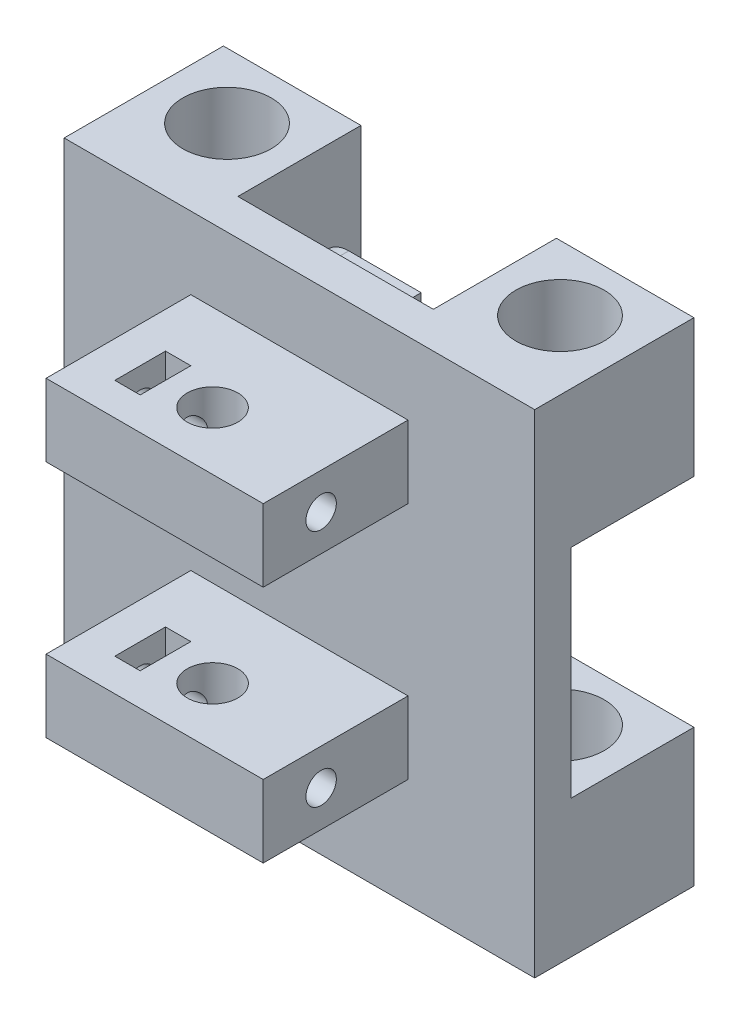
from build123d import *

# Parameters (mm, degrees)
SKETCH1_W           = 19
SKETCH1_H           = 17
SKETCH1_R           = 6.1
BOSS_EXTRUDE1_DEPTH = 68
SKETCH3_W           = 65
SKETCH3_H           = 30
CUT_EXTRUDE1_DEPTH  = 17
SKETCH4_W           = 5
SKETCH4_H           = 4
BOSS_EXTRUDE2_DEPTH = 3
SKETCH5_W           = 30
SKETCH5_H           = 10
BOSS_EXTRUDE3_DEPTH = 20
SKETCH6_R           = 3.5
CUT_EXTRUDE2_DEPTH  = 59
SKETCH8_R           = 2.1
CUT_EXTRUDE3_DEPTH  = 48.5
SKETCH9_W           = 3.5
SKETCH9_H           = 7
CUT_EXTRUDE4_DEPTH  = 43


with BuildPart() as part:
    # Sketch1 → Boss-Extrude1 (new body)
    with BuildSketch(Plane(origin=(0, 0, 0), x_dir=(1, 0, 0), z_dir=(0, 1, 0))):
        with Locations((-23, 0.5)):
            Rectangle(SKETCH1_W, SKETCH1_H)
        with Locations((-23, 0)):
            Circle(SKETCH1_R, mode=Mode.SUBTRACT)
        with Locations((23, 0.5)):
            Rectangle(SKETCH1_W, SKETCH1_H)
        with Locations((23, 0)):
            Circle(SKETCH1_R, mode=Mode.SUBTRACT)
        Polygon((-13.5, -8), (13.5, -8), (32.5, -8), (32.5, -13), (-32.5, -13), (-32.5, -8), align=None)
    extrude(amount=BOSS_EXTRUDE1_DEPTH)

    # Sketch3 → Cut-Extrude1 (cut)
    with BuildSketch(Plane(origin=(0, 0, -9), x_dir=(-1, 0, 0), z_dir=(0, 0, -1))):
        with Locations((0, 34)):
            Rectangle(SKETCH3_W, SKETCH3_H)
    extrude(amount=-CUT_EXTRUDE1_DEPTH, mode=Mode.SUBTRACT)

    # Sketch4 → Boss-Extrude2 (add)
    with BuildSketch(Plane(origin=(0, 0, 8), x_dir=(-1, 0, 0), z_dir=(0, 0, -1))):
        with BuildLine():
            ThreePointArc((4.191236083, 59.518146972), (4.82097308, 63.804174702), (1.17903595, 66.15))
            Line((1.17903595, 66.15), (-8.82096405, 66.15))
            Line((-8.82096405, 66.15), (-8.82096405, 62.15))
            Line((-8.82096405, 62.15), (1.17903595, 62.15))
            ThreePointArc((1.17903595, 62.15), (3.230210626, 61.45792056), (4.191236083, 59.518146972))
        make_face()
        with Locations((-6.32096405, 56.15)):
            Rectangle(SKETCH4_W, SKETCH4_H)
    extrude(amount=BOSS_EXTRUDE2_DEPTH)

    # Sketch5 → Boss-Extrude3 (add)
    with BuildSketch(Plane.XY.offset(13)):
        with Locations((0, 20)):
            Rectangle(SKETCH5_W, SKETCH5_H)
        with Locations((0, 53)):
            Rectangle(SKETCH5_W, SKETCH5_H)
    extrude(amount=BOSS_EXTRUDE3_DEPTH)

    # Sketch6 → Cut-Extrude2 (cut, through all)
    with BuildSketch(Plane(origin=(0, 58, 0), x_dir=(1, 0, 0), z_dir=(0, 1, 0))):
        with Locations((0, -25)):
            Circle(SKETCH6_R)
    extrude(amount=-CUT_EXTRUDE2_DEPTH, mode=Mode.SUBTRACT)

    # Sketch8 → Cut-Extrude3 (cut, through all)
    with BuildSketch(Plane.ZY.offset(15)):
        with Locations((25, 20)):
            Circle(SKETCH8_R)
        with Locations((25, 53)):
            Circle(SKETCH8_R)
    extrude(amount=-CUT_EXTRUDE3_DEPTH, mode=Mode.SUBTRACT)

    # Sketch9 → Cut-Extrude4 (cut)
    with BuildSketch(Plane.XZ.offset(-15)):
        with Locations((-8.25, 25)):
            Rectangle(SKETCH9_W, SKETCH9_H)
    extrude(amount=-CUT_EXTRUDE4_DEPTH, mode=Mode.SUBTRACT)


solid = part.part
